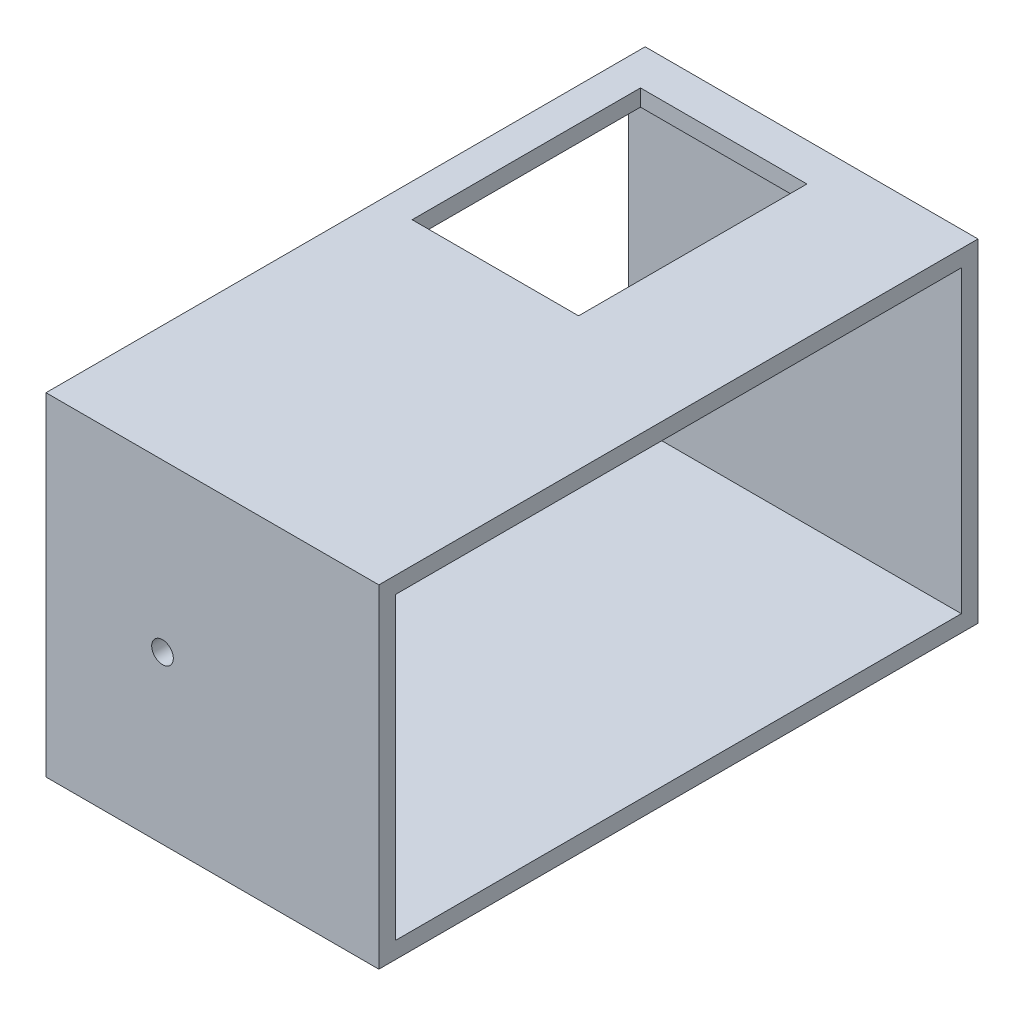
from build123d import *

# Parameters (mm, degrees)
SKETCH_1_W               = 100
SKETCH_1_H               = 180
EXTRUDE_1_DEPTH          = 100
SKETCH_2_W               = 50
SKETCH_2_H               = 68.6
CUT_EXTRUDE_1_DEPTH      = 90
SKETCH_3_W               = 170
SKETCH_3_H               = 90
CUT_EXTRUDE_2_DEPTH      = 101
SKETCH_4_R               = 3.25
CUT_EXTRUDE_3_DEPTH      = 1
CUT_EXTRUDE_3_DEPTH_BACK = 181


with BuildPart() as part:
    # 草图1 → 凸台-拉伸1 (new body)
    with BuildSketch(Plane(origin=(0, 0, 0), x_dir=(1, 0, 0), z_dir=(0, 1, 0))):
        Rectangle(SKETCH_1_W, SKETCH_1_H)
    extrude(amount=EXTRUDE_1_DEPTH)

    # 草图2 → 切除-拉伸1 (cut)
    with BuildSketch(Plane(origin=(0, 100, 0), x_dir=(1, 0, 0), z_dir=(0, 1, 0))):
        with Locations((-15, 44.3)):
            Rectangle(SKETCH_2_W, SKETCH_2_H)
    extrude(amount=-CUT_EXTRUDE_1_DEPTH, mode=Mode.SUBTRACT)

    # 草图3 → 切除-拉伸2 (cut, through all)
    with BuildSketch(Plane.ZY.offset(50)):
        with Locations((0, 50)):
            Rectangle(SKETCH_3_W, SKETCH_3_H)
    extrude(amount=-CUT_EXTRUDE_2_DEPTH, mode=Mode.SUBTRACT)

    # 草图4 → 切除-拉伸3 (cut, two sides)
    with BuildSketch(Plane.XY.offset(90)) as cut_extrude_3_sk:
        with Locations((-15, 50)):
            Circle(SKETCH_4_R)
    extrude(amount=CUT_EXTRUDE_3_DEPTH, mode=Mode.SUBTRACT)
    extrude(cut_extrude_3_sk.sketch, amount=-CUT_EXTRUDE_3_DEPTH_BACK, mode=Mode.SUBTRACT)


solid = part.part
